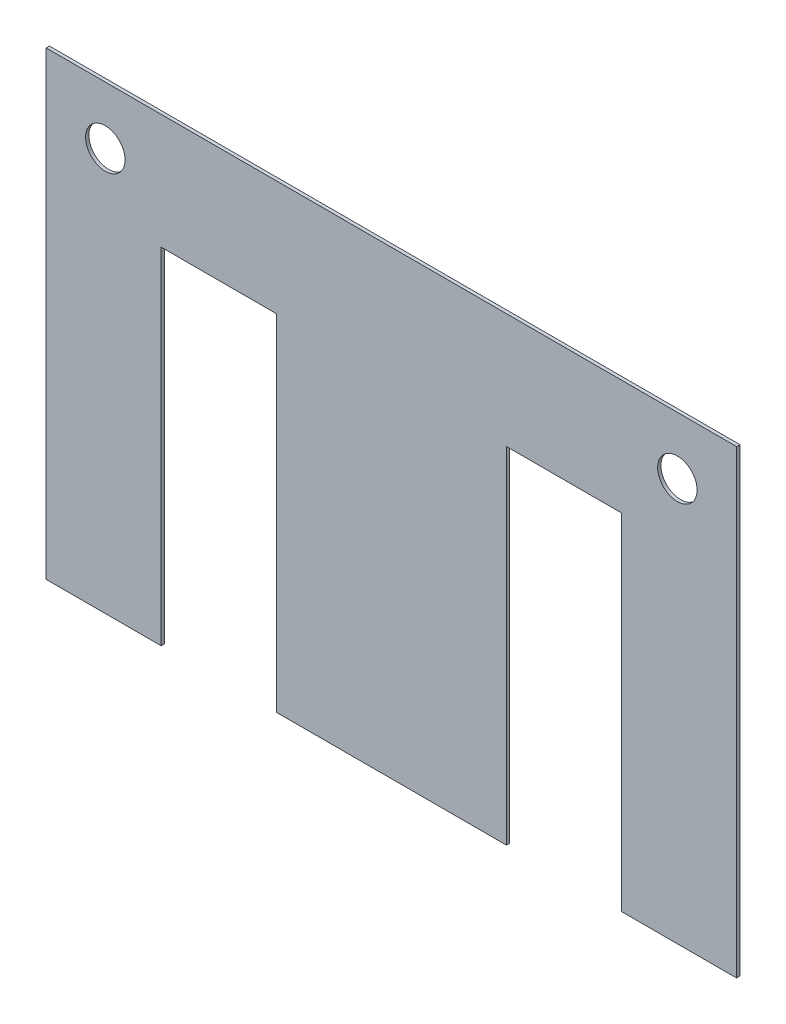
from build123d import *

# Parameters (mm, degrees)
SKETCH1_R           = 3
BOSS_EXTRUDE1_DEPTH = 0.5


with BuildPart() as part:
    # Sketch1 → Boss-Extrude1 (new body)
    with BuildSketch(Plane.XY):
        Polygon((0, 0), (0, 70), (105, 70), (105, 0), (87.5, 0), (87.5, 52.5), (70, 52.5), (70, 0), (35, 0), (35, 52.5), (17.5, 52.5), (17.5, 0), align=None)
        with Locations((9, 61.25)):
            Circle(SKETCH1_R, mode=Mode.SUBTRACT)
        with Locations((96, 61.25)):
            Circle(SKETCH1_R, mode=Mode.SUBTRACT)
    extrude(amount=BOSS_EXTRUDE1_DEPTH)


solid = part.part
